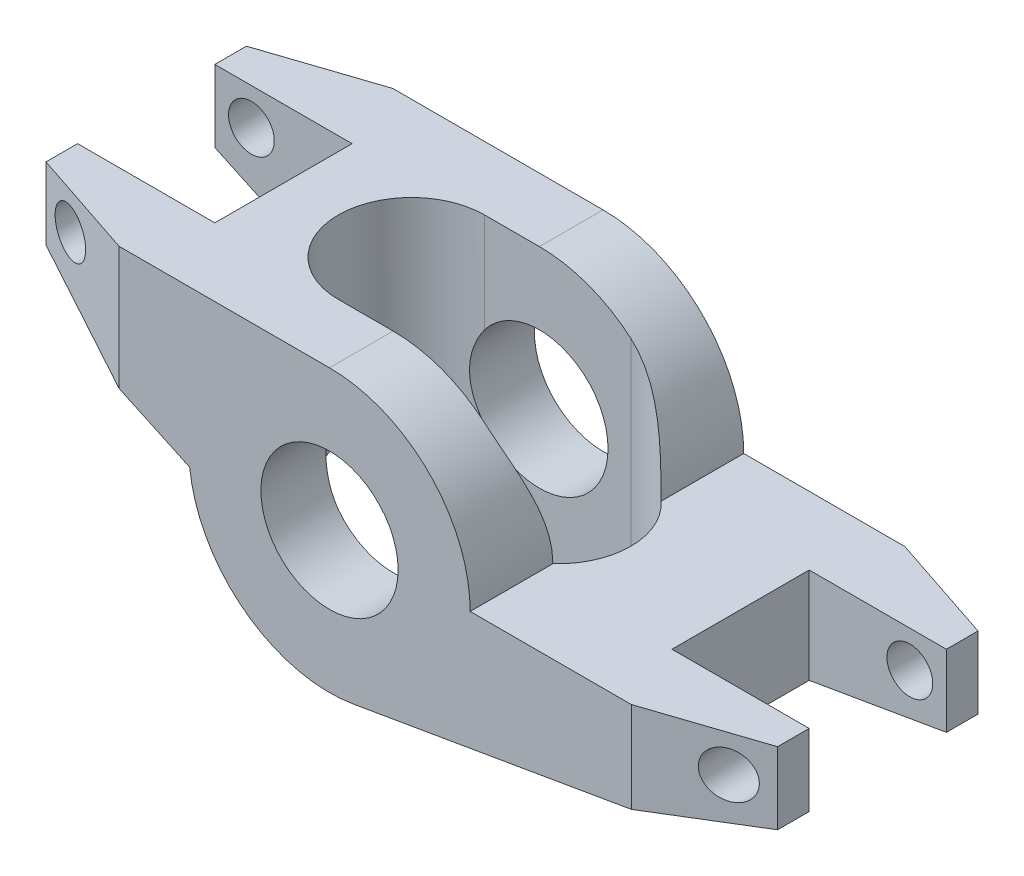
from build123d import *

# Parameters (mm, degrees)
SKETCH1_R               = 4.765
BOSS_EXTRUDE1_DEPTH     = 9.5
CHAMFER1_SIZE           = 7.62
CHAMFER1_SIZE2          = 2.54
CHAMFER2_SIZE           = 2.54
CHAMFER2_SIZE2          = 7.62
CHAMFER2_PART_2_SIZE    = 2.54
CHAMFER2_PART_2_SIZE2   = 7.62
SKETCH5_W               = 9.53
SKETCH5_H               = 9.53
CUT_EXTRUDE1_DEPTH      = 20.54
CUT_EXTRUDE2_DEPTH      = 10.77
CUT_EXTRUDE2_DEPTH_BACK = 10.77
SKETCH7_R               = 1.59
CUT_EXTRUDE3_DEPTH      = 10.5000001
CUT_EXTRUDE3_DEPTH_BACK = 10.5000001


with BuildPart() as part:
    # Sketch1 → Boss-Extrude1 (new body, symmetric)
    with BuildSketch(Plane.XY):
        with BuildLine():
            Line((0, 9.77), (-22.23, 9.77))
            Line((-22.23, 9.77), (-22.23, 4.77))
            Line((-22.23, 4.77), (-9.711509246, -1.067468107))
            ThreePointArc((-9.711509246, -1.067468107), (-5.877874817, -7.804068659), (1.655323868, -9.628748771))
            Line((1.655323868, -9.628748771), (28.58, -5))
            Line((28.58, -5), (28.58, 0))
            Line((28.58, 0), (9.77, 0))
            ThreePointArc((9.77, 0), (6.908433252, 6.908433252), (0, 9.77))
        make_face()
        Circle(SKETCH1_R, mode=Mode.SUBTRACT)
    extrude(amount=BOSS_EXTRUDE1_DEPTH, both=True)

    # Chamfer1
    chamfer1_edges = [part.edges().sort_by_distance(p)[0] for p in [
        (-22.23, 7.27, -9.5),
        (28.58, -2.5, -9.5),
    ]]
    chamfer1_side = [part.faces().sort_by_distance(p)[0] for p in [
        (-11.115, 9.225622585, -9.5),
    ]]
    chamfer(chamfer1_edges, length=CHAMFER1_SIZE, length2=CHAMFER1_SIZE2, reference=chamfer1_side[0])

    # Chamfer2
    chamfer2_edges = [part.edges().sort_by_distance(p)[0] for p in [
        (-22.23, 7.27, 9.5),
    ]]
    chamfer2_side = [part.faces().sort_by_distance(p)[0] for p in [
        (-22.23, 7.27, 1.27),
    ]]
    chamfer(chamfer2_edges, length=CHAMFER2_SIZE, length2=CHAMFER2_SIZE2, reference=chamfer2_side[0])

    # Chamfer2 part 2
    chamfer2_part_2_edges = [part.edges().sort_by_distance(p)[0] for p in [
        (28.58, -2.5, 9.5),
    ]]
    chamfer2_part_2_side = [part.faces().sort_by_distance(p)[0] for p in [
        (28.58, -2.5, 1.27),
    ]]
    chamfer(chamfer2_part_2_edges, length=CHAMFER2_PART_2_SIZE, length2=CHAMFER2_PART_2_SIZE2, reference=chamfer2_part_2_side[0])

    # Sketch5 → Cut-Extrude1 (cut, through all)
    with BuildSketch(Plane(origin=(0, 9.77, 0), x_dir=(1, 0, 0), z_dir=(0, 1, 0))):
        with Locations((-17.465, 0)):
            Rectangle(SKETCH5_W, SKETCH5_H)
        with Locations((23.815, 0)):
            Rectangle(SKETCH5_W, SKETCH5_H)
    extrude(amount=-CUT_EXTRUDE1_DEPTH, mode=Mode.SUBTRACT)

    # Sketch6 → Cut-Extrude2 (cut, two sides)
    with BuildSketch(Plane(origin=(0, 0, 0), x_dir=(1, 0, 0), z_dir=(0, 1, 0))) as cut_extrude2_sk:
        with BuildLine():
            Line((-3.81, 5.08), (6.35, 5.08))
            ThreePointArc((6.35, 5.08), (11.43, 0), (6.35, -5.08))
            Line((6.35, -5.08), (-3.81, -5.08))
            ThreePointArc((-3.81, -5.08), (-8.89, 0), (-3.81, 5.08))
        make_face()
    extrude(amount=CUT_EXTRUDE2_DEPTH, mode=Mode.SUBTRACT)
    extrude(cut_extrude2_sk.sketch, amount=-CUT_EXTRUDE2_DEPTH_BACK, mode=Mode.SUBTRACT)

    # Sketch7 → Cut-Extrude3 (cut, two sides)
    with BuildSketch(Plane.XY) as cut_extrude3_sk:
        with Locations((-19.69, 7.23)):
            Circle(SKETCH7_R)
        with Locations((26.04, -2.54)):
            Circle(SKETCH7_R)
    extrude(amount=CUT_EXTRUDE3_DEPTH, mode=Mode.SUBTRACT)
    extrude(cut_extrude3_sk.sketch, amount=-CUT_EXTRUDE3_DEPTH_BACK, mode=Mode.SUBTRACT)


solid = part.part
